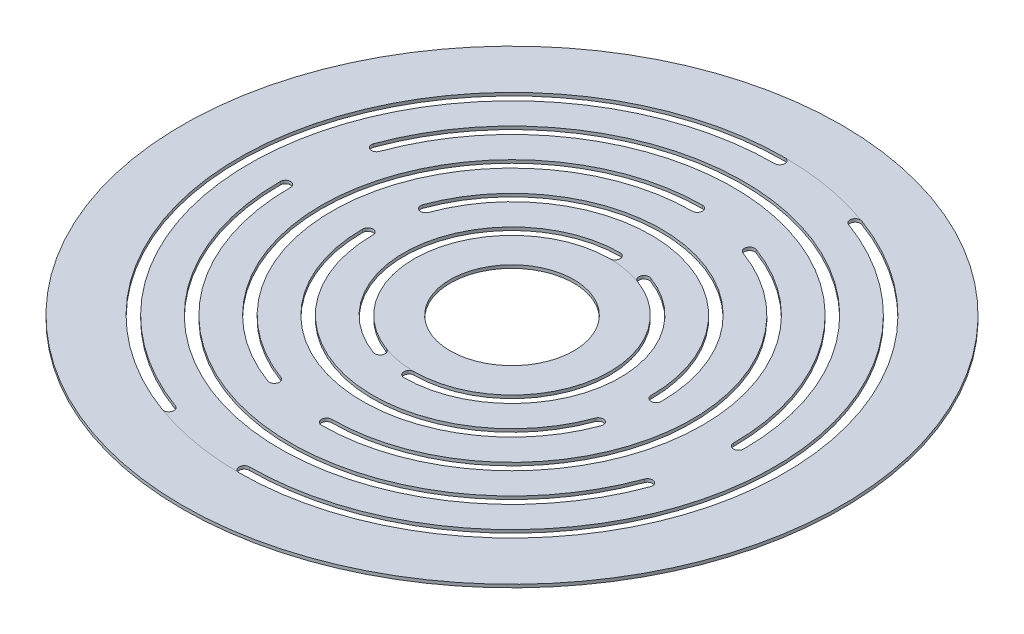
from build123d import *

# Parameters (mm, degrees)
SKETCH1_R           = 32
SKETCH1_R_2         = 6
BOSS_EXTRUDE1_DEPTH = 0.3


with BuildPart() as part:
    # Sketch1 → Boss-Extrude1 (new body)
    with BuildSketch(Plane(origin=(0, 0, 0), x_dir=(1, 0, 0), z_dir=(0, 1, 0))):
        Circle(SKETCH1_R)
        Circle(SKETCH1_R_2, mode=Mode.SUBTRACT)
        with BuildLine():
            ThreePointArc((0, 26.5), (-26.097405455, 4.601676708), (-9.063533798, -24.901854451))
            ThreePointArc((-9.063533798, -24.901854451), (-8.422677416, -24.603018212), (-8.721513655, -23.96216183))
            ThreePointArc((-8.721513655, -23.96216183), (-25.112597702, 4.428028531), (0, 25.5))
            ThreePointArc((0, 25.5), (0.5, 26), (0, 26.5))
        make_face(mode=Mode.SUBTRACT)
        with BuildLine():
            ThreePointArc((22.5, 0), (3.907083998, 22.158174443), (-21.143083968, 7.695453225))
            ThreePointArc((-21.143083968, 7.695453225), (-20.844247729, 7.054596843), (-20.203391347, 7.353433082))
            ThreePointArc((-20.203391347, 7.353433082), (3.73343582, 21.17336669), (21.5, 0))
            ThreePointArc((21.5, 0), (22, -0.5), (22.5, 0))
        make_face(mode=Mode.SUBTRACT)
        with BuildLine():
            ThreePointArc((0, -26.5), (26.097405455, -4.601676708), (9.063533798, 24.901854451))
            ThreePointArc((9.063533798, 24.901854451), (8.422677416, 24.603018212), (8.721513655, 23.96216183))
            ThreePointArc((8.721513655, 23.96216183), (25.112597702, -4.428028531), (0, -25.5))
            ThreePointArc((0, -25.5), (-0.5, -26), (0, -26.5))
        make_face(mode=Mode.SUBTRACT)
        with BuildLine():
            ThreePointArc((0, 18.5), (-18.218943431, 3.212491287), (-6.327372652, -17.384313485))
            ThreePointArc((-6.327372652, -17.384313485), (-5.686516269, -17.085477246), (-5.985352508, -16.444620864))
            ThreePointArc((-5.985352508, -16.444620864), (-17.234135678, 3.038843109), (0, 17.5))
            ThreePointArc((0, 17.5), (0.5, 18), (0, 18.5))
        make_face(mode=Mode.SUBTRACT)
        with BuildLine():
            ThreePointArc((14.5, 0), (2.517898576, 14.279712419), (-13.625543001, 4.959292078))
            ThreePointArc((-13.625543001, 4.959292078), (-13.326706763, 4.318435696), (-12.685850381, 4.617271935))
            ThreePointArc((-12.685850381, 4.617271935), (2.344250399, 13.294904666), (13.5, 0))
            ThreePointArc((13.5, 0), (14, -0.5), (14.5, 0))
        make_face(mode=Mode.SUBTRACT)
        with BuildLine():
            ThreePointArc((0, -18.5), (18.218943431, -3.212491287), (6.327372652, 17.384313485))
            ThreePointArc((6.327372652, 17.384313485), (5.686516269, 17.085477246), (5.985352508, 16.444620864))
            ThreePointArc((5.985352508, 16.444620864), (17.234135678, -3.038843109), (0, -17.5))
            ThreePointArc((0, -17.5), (-0.5, -18), (0, -18.5))
        make_face(mode=Mode.SUBTRACT)
        with BuildLine():
            ThreePointArc((0, 10.5), (-10.340481407, 1.823305866), (-3.591211505, -9.866772518))
            ThreePointArc((-3.591211505, -9.866772518), (-2.950355123, -9.56793628), (-3.249191362, -8.927079897))
            ThreePointArc((-3.249191362, -8.927079897), (-9.355673654, 1.649657688), (0, 9.5))
            ThreePointArc((0, 9.5), (0.5, 10), (0, 10.5))
        make_face(mode=Mode.SUBTRACT)
        with BuildLine():
            ThreePointArc((0, -10.5), (10.340481407, -1.823305866), (3.591211505, 9.866772518))
            ThreePointArc((3.591211505, 9.866772518), (2.950355123, 9.56793628), (3.249191362, 8.927079897))
            ThreePointArc((3.249191362, 8.927079897), (9.355673654, -1.649657688), (0, -9.5))
            ThreePointArc((0, -9.5), (-0.5, -10), (0, -10.5))
        make_face(mode=Mode.SUBTRACT)
        with BuildLine():
            ThreePointArc((-14.5, 0), (-2.517898576, -14.279712419), (13.625543001, -4.959292078))
            ThreePointArc((13.625543001, -4.959292078), (13.326706763, -4.318435696), (12.685850381, -4.617271935))
            ThreePointArc((12.685850381, -4.617271935), (-2.344250399, -13.294904666), (-13.5, 0))
            ThreePointArc((-13.5, 0), (-14, 0.5), (-14.5, 0))
        make_face(mode=Mode.SUBTRACT)
        with BuildLine():
            ThreePointArc((-22.5, 0), (-3.907083998, -22.158174443), (21.143083968, -7.695453225))
            ThreePointArc((21.143083968, -7.695453225), (20.844247729, -7.054596843), (20.203391347, -7.353433082))
            ThreePointArc((20.203391347, -7.353433082), (-3.73343582, -21.17336669), (-21.5, 0))
            ThreePointArc((-21.5, 0), (-22, 0.5), (-22.5, 0))
        make_face(mode=Mode.SUBTRACT)
    extrude(amount=BOSS_EXTRUDE1_DEPTH)


solid = part.part
